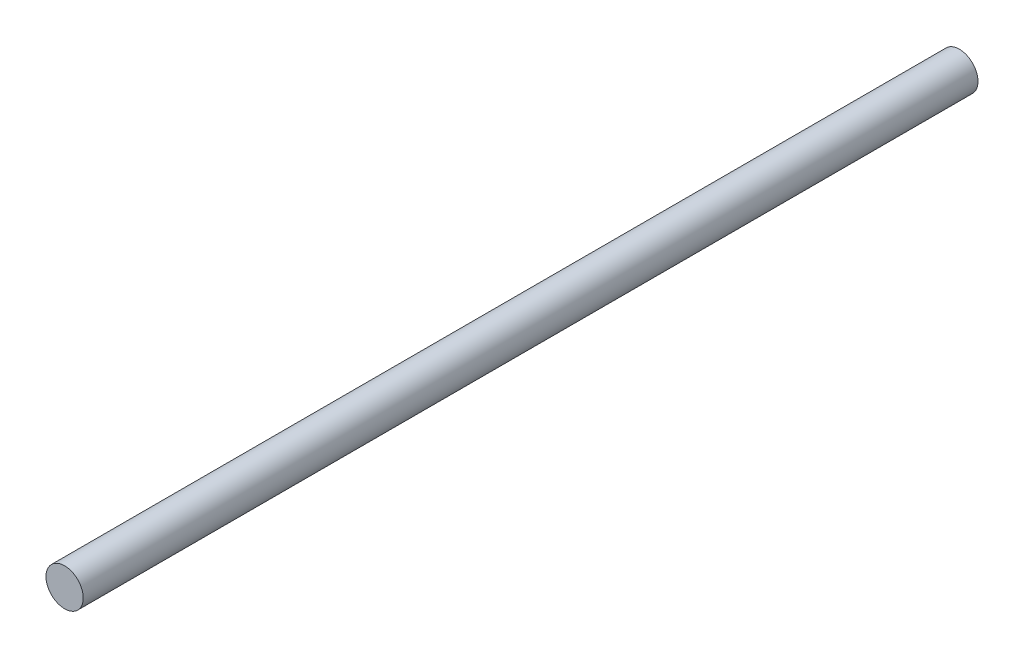
from build123d import *

# Parameters (mm, degrees)
VARREDURA1_PROFILE_R = 1.25


with BuildPart() as part:
    # Varredura1: sweep along a path in Esboço1
    with BuildLine(Plane(origin=(0, 0, 0), x_dir=(1, 0, 0), z_dir=(0, 1, 0))) as varredura1_path:
        Line((0, 30), (0, -30))
    # Varredura1 profile (on start of the path) → Varredura1 (sweep)
    with BuildSketch(Plane.XY.offset(-30)):
        Circle(VARREDURA1_PROFILE_R)
    sweep(path=varredura1_path.line)


solid = part.part
